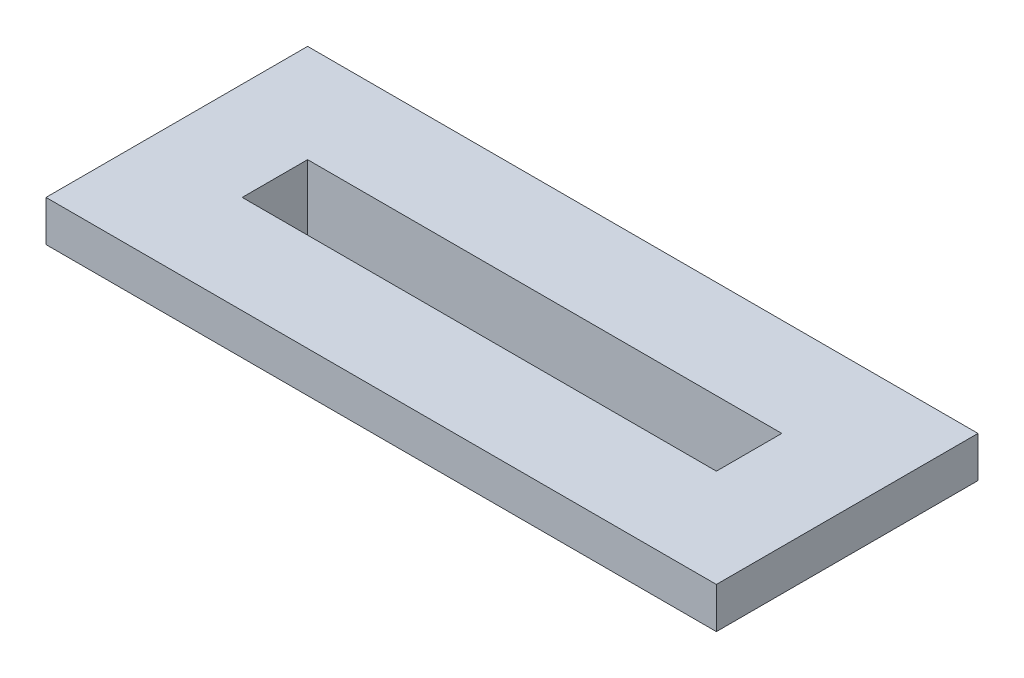
from build123d import *

# Parameters (mm, degrees)
BOSS_EXTRUDE1_DEPTH      = 40
BOSS_EXTRUDE1_DEPTH_BACK = 10
SKETCH1_W                = 820
SKETCH1_H                = 320
SKETCH1_W_2              = 580
SKETCH1_H_2              = 80
SKETCH1_4_W              = 700
SKETCH1_4_H              = 200
SKETCH1_4_W_2            = 580
SKETCH1_4_H_2            = 80
BOSS_EXTRUDE2_DEPTH      = 40


with BuildPart() as part:
    # Sketch1 → Boss-Extrude1 (new, two sides: drawn at the far end of the back side and taken through both)
    with BuildSketch(Plane(origin=(0, 0, 0), x_dir=(1, 0, 0), z_dir=(0, 1, 0)).offset(-BOSS_EXTRUDE1_DEPTH_BACK)):
        Rectangle(SKETCH1_W, SKETCH1_H)
        Rectangle(SKETCH1_W_2, SKETCH1_H_2, mode=Mode.SUBTRACT)
    extrude(amount=BOSS_EXTRUDE1_DEPTH + BOSS_EXTRUDE1_DEPTH_BACK)

    # Sketch1_4 → Boss-Extrude2 (add)
    with BuildSketch(Plane(origin=(0, 0, 0), x_dir=(1, 0, 0), z_dir=(0, 1, 0))):
        Rectangle(SKETCH1_4_W, SKETCH1_4_H)
        Rectangle(SKETCH1_4_W_2, SKETCH1_4_H_2, mode=Mode.SUBTRACT)
    extrude(amount=-BOSS_EXTRUDE2_DEPTH)


solid = part.part
